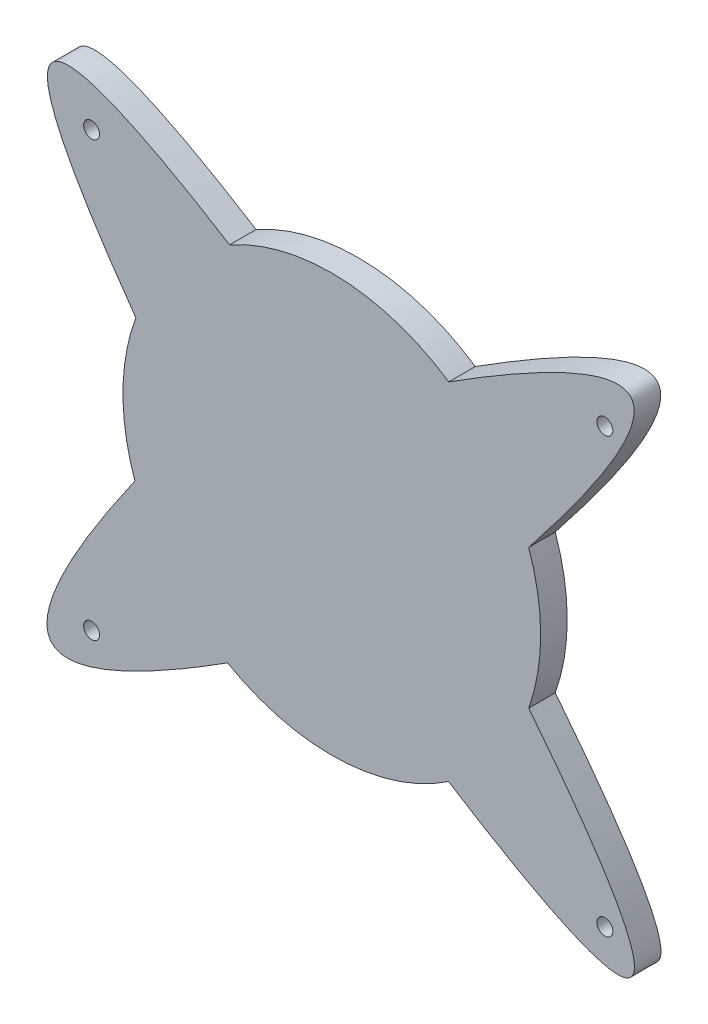
from build123d import *

# Parameters (mm, degrees)
SKETCH2_R           = 0.9
BOSS_EXTRUDE1_DEPTH = 3


with BuildPart() as part:
    # Sketch2 → Boss-Extrude1 (new body)
    with BuildSketch(Plane.XY):
        with BuildLine():
            add(Edge.make_bspline(
                [(-34.002851303, 8.604476718), (-58.333457607, 42.758566595), (-23.407809103, 21.030549249)],
                knots=[0, 0, 0, 1, 1, 1], degree=2))
            ThreePointArc((-34.002851303, 8.604476718), (-35.455837584, 0.600929894), (-34.105332305, -7.42054543))
            add(Edge.make_bspline(
                [(-34.105332305, -7.42054543), (-58.281676493, -42.050918016), (-23.642702616, -19.996916463)],
                knots=[0, 0, 0, 1, 1, 1], degree=2))
            ThreePointArc((-23.642702616, -19.996916463), (-11.029350737, -23.137049671), (1.333618717, -19.122816437))
            add(Edge.make_bspline(
                [(10.40030161, -7.407444616), (38.188248564, -42.452256001), (1.333618717, -19.122816437)],
                knots=[0, 0, 0, 1, 1, 1], degree=2))
            ThreePointArc((10.40030161, -7.407444616), (11.746657416, 0.460490628), (10.393307704, 8.32722588))
            add(Edge.make_bspline(
                [(10.393307704, 8.32722588), (38.116592963, 43.308207972), (1.359443986, 20.005390199)],
                knots=[0.00410137, 0.00410137, 0.00410137, 0.997962678, 0.997962678, 0.997962678], degree=2))
            ThreePointArc((1.359443986, 20.005390199), (-10.878759881, 24.031297997), (-23.407809103, 21.030549249))
        make_face()
        with Locations((-39, -24.5)):
            Circle(SKETCH2_R, mode=Mode.SUBTRACT)
        with Locations((19, -24.5)):
            Circle(SKETCH2_R, mode=Mode.SUBTRACT)
        with Locations((-39, 24.5)):
            Circle(SKETCH2_R, mode=Mode.SUBTRACT)
        with Locations((19, 24.5)):
            Circle(SKETCH2_R, mode=Mode.SUBTRACT)
    extrude(amount=BOSS_EXTRUDE1_DEPTH)


solid = part.part
